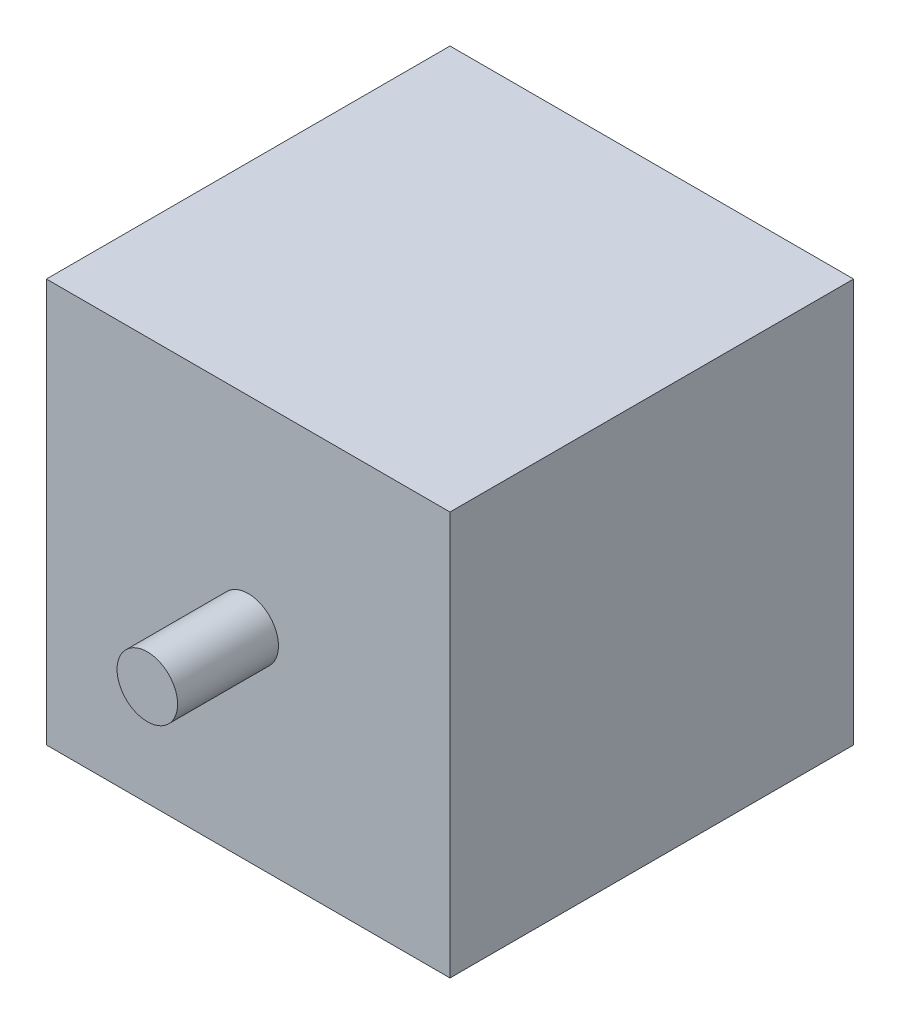
from build123d import *

# Parameters (mm, degrees)
SKETCH1_W           = 40
SKETCH1_H           = 40
BOSS_EXTRUDE1_DEPTH = 40
SKETCH2_R           = 3
BOSS_EXTRUDE2_DEPTH = 10


with BuildPart() as part:
    # Sketch1 → Boss-Extrude1 (new body)
    with BuildSketch(Plane.XY):
        Rectangle(SKETCH1_W, SKETCH1_H)
    extrude(amount=BOSS_EXTRUDE1_DEPTH)

    # Sketch2 → Boss-Extrude2 (add)
    with BuildSketch(Plane.XY.offset(40)):
        Circle(SKETCH2_R)
    extrude(amount=BOSS_EXTRUDE2_DEPTH)


solid = part.part
